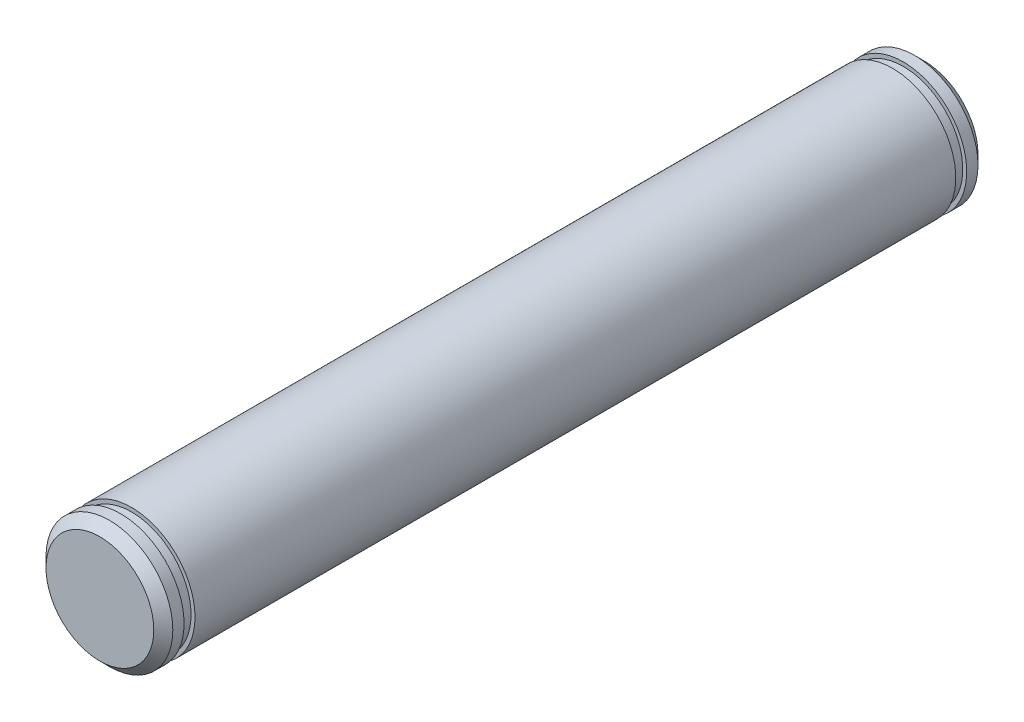
from build123d import *

# Parameters (mm, degrees)
SKETCH1_R           = 12.7
BOSS_EXTRUDE1_DEPTH = 165.1
SKETCH2_W           = 0.7874
SKETCH2_H           = 2.1844
CHAMFER1_SIZE       = 1.905


with BuildPart() as part:
    # Sketch1 → Boss-Extrude1 (new body)
    with BuildSketch(Plane.XY):
        Circle(SKETCH1_R)
    extrude(amount=BOSS_EXTRUDE1_DEPTH)

    # Sketch2 → Cut-Revolve1 (revolve, cut)
    with BuildSketch(Plane(origin=(0, 0, 0), x_dir=(1, 0, 0), z_dir=(0, 1, 0))):
        with Locations((-12.3063, -5.2578)):
            Rectangle(SKETCH2_W, SKETCH2_H)
        with Locations((-12.3063, -159.8422)):
            Rectangle(SKETCH2_W, SKETCH2_H)
    revolve(axis=Axis((0, 0, 0), (0, 0, 1)), mode=Mode.SUBTRACT)

    # Chamfer1
    chamfer1_edges = [part.edges().sort_by_distance(p)[0] for p in [
        (-12.7, 0, 0),
        (-12.7, 0, 165.1),
    ]]
    chamfer(chamfer1_edges, length=CHAMFER1_SIZE)


solid = part.part
